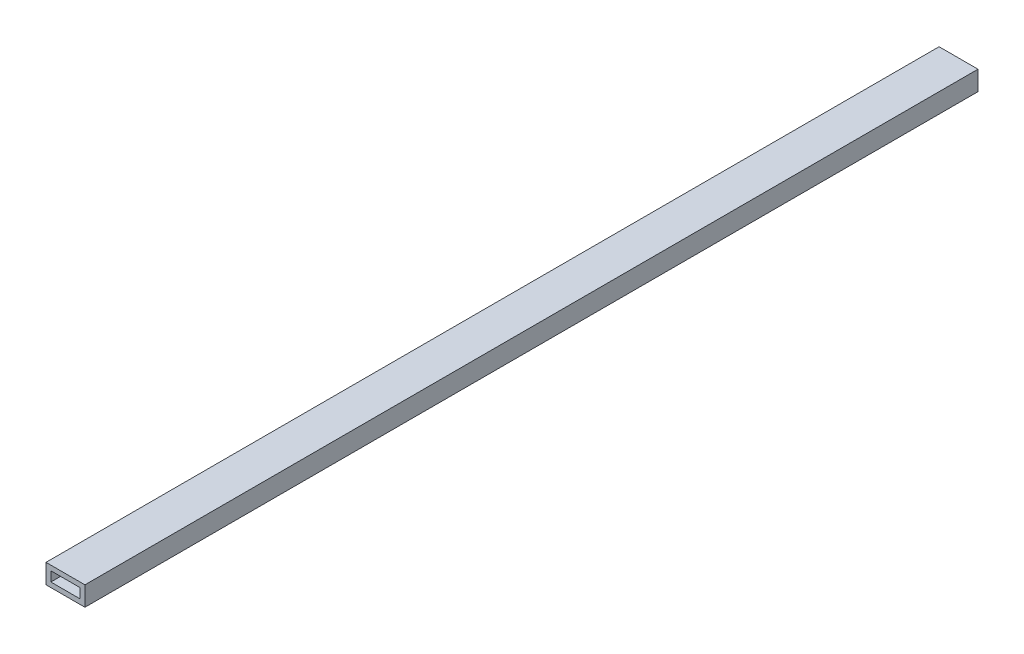
from build123d import *

# Parameters (mm, degrees)
SKETCH1_W           = 25.4
SKETCH1_H           = 12.7
BOSS_EXTRUDE1_DEPTH = 582.676
SKETCH2_W           = 19.05
SKETCH2_H           = 6.35
CUT_EXTRUDE1_DEPTH  = 583.676


with BuildPart() as part:
    # Sketch1 → Boss-Extrude1 (new body)
    with BuildSketch(Plane.XY):
        with Locations((-12.584193343, 8.563919414)):
            Rectangle(SKETCH1_W, SKETCH1_H)
    extrude(amount=BOSS_EXTRUDE1_DEPTH)

    # Sketch2 → Cut-Extrude1 (cut, through all)
    with BuildSketch(Plane(origin=(0, 0, 0), x_dir=(-1, 0, 0), z_dir=(0, 0, -1))):
        with Locations((12.584193343, 8.563919414)):
            Rectangle(SKETCH2_W, SKETCH2_H)
    extrude(amount=-CUT_EXTRUDE1_DEPTH, mode=Mode.SUBTRACT)


solid = part.part
